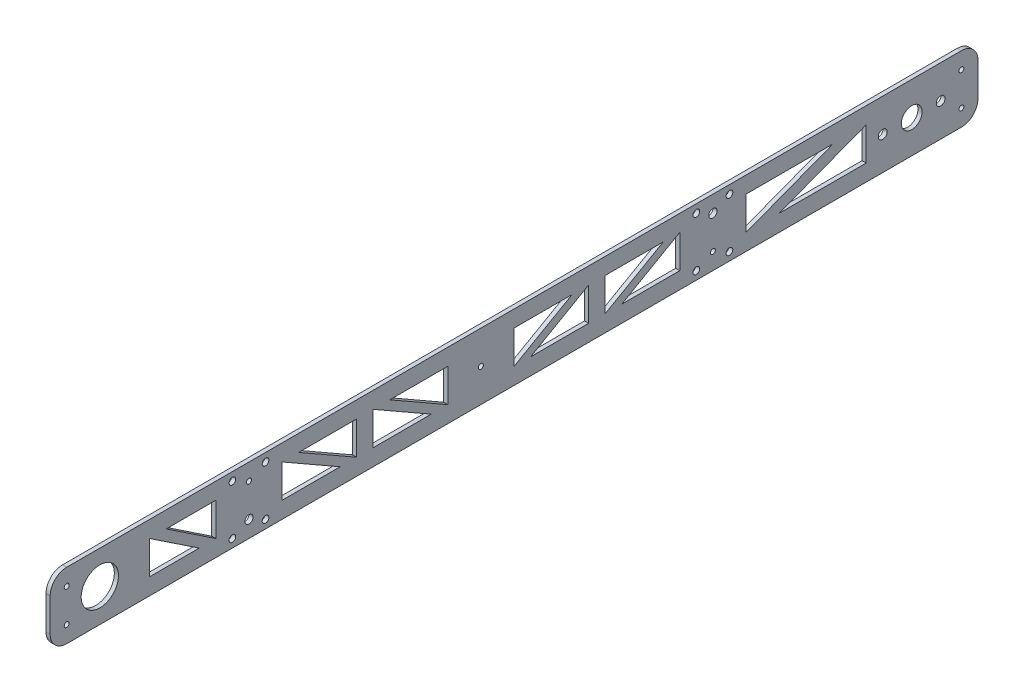
from build123d import *

# Parameters (mm, degrees)
SKETCH1_R           = 7.9629
SKETCH1_R_2         = 3.3782
SKETCH1_R_3         = 2.5527
SKETCH1_R_4         = 14.2875
SKETCH1_R_5         = 1.89865
SKETCH1_R_6         = 3.1496
SKETCH1_R_7         = 3.175
BOSS_EXTRUDE1_DEPTH = 3.175


with BuildPart() as part:
    # Sketch1 → Boss-Extrude1 (new body)
    with BuildSketch(Plane(origin=(0, 0, 0), x_dir=(0, 0, -1), z_dir=(1, 0, 0))):
        with BuildLine():
            Line((-12.7, 0), (-698.5, 0))
            ThreePointArc((-698.5, 0), (-707.480256121, 3.719743879), (-711.2, 12.7))
            Line((-711.2, 12.7), (-711.2, 38.1))
            ThreePointArc((-711.2, 38.1), (-707.480256121, 47.080256121), (-698.5, 50.8))
            Line((-698.5, 50.8), (-12.7, 50.8))
            ThreePointArc((-12.7, 50.8), (-3.719743879, 47.080256121), (0, 38.1))
            Line((0, 38.1), (0, 12.7))
            ThreePointArc((0, 12.7), (-3.719743879, 3.719743879), (-12.7, 0))
        make_face()
        with Locations((-50.8, 25.4)):
            Circle(SKETCH1_R, mode=Mode.SUBTRACT)
        with Locations((-28.575, 25.4)):
            Circle(SKETCH1_R_2, mode=Mode.SUBTRACT)
        with Locations((-215.9, 44.45)):
            Circle(SKETCH1_R_3, mode=Mode.SUBTRACT)
        with Locations((-190.5, 44.45)):
            Circle(SKETCH1_R_3, mode=Mode.SUBTRACT)
        with Locations((-190.5, 6.35)):
            Circle(SKETCH1_R_3, mode=Mode.SUBTRACT)
        with Locations((-215.9, 6.35)):
            Circle(SKETCH1_R_3, mode=Mode.SUBTRACT)
        with Locations((-73.025, 25.4)):
            Circle(SKETCH1_R_2, mode=Mode.SUBTRACT)
        with Locations((-673.1, 25.4)):
            Circle(SKETCH1_R_4, mode=Mode.SUBTRACT)
        with Locations((-571.5, 44.45)):
            Circle(SKETCH1_R_3, mode=Mode.SUBTRACT)
        with Locations((-546.1, 44.45)):
            Circle(SKETCH1_R_3, mode=Mode.SUBTRACT)
        with Locations((-12.7, 38.1)):
            Circle(SKETCH1_R_5, mode=Mode.SUBTRACT)
        with Locations((-12.7, 12.7)):
            Circle(SKETCH1_R_5, mode=Mode.SUBTRACT)
        with Locations((-546.1, 6.35)):
            Circle(SKETCH1_R_3, mode=Mode.SUBTRACT)
        with Locations((-571.5, 6.35)):
            Circle(SKETCH1_R_3, mode=Mode.SUBTRACT)
        with Locations((-558.8, 12.7)):
            Circle(SKETCH1_R_6, mode=Mode.SUBTRACT)
        with Locations((-203.2, 38.1)):
            Circle(SKETCH1_R_7, mode=Mode.SUBTRACT)
        with Locations((-698.5, 38.1)):
            Circle(SKETCH1_R_5, mode=Mode.SUBTRACT)
        with Locations((-698.5, 12.7)):
            Circle(SKETCH1_R_5, mode=Mode.SUBTRACT)
        with Locations((-558.8, 38.1)):
            Circle(SKETCH1_R_5, mode=Mode.SUBTRACT)
        with Locations((-203.2, 12.7)):
            Circle(SKETCH1_R_5, mode=Mode.SUBTRACT)
        with Locations((-381, 25.4)):
            Circle(SKETCH1_R_5, mode=Mode.SUBTRACT)
        Polygon((-228.6, 38.1), (-228.6, 12.7), (-273.05, 12.7), align=None, mode=Mode.SUBTRACT)
        Polygon((-635, 38.1), (-635, 12.7), (-596.9, 12.7), align=None, mode=Mode.SUBTRACT)
        Polygon((-622.3, 38.1), (-584.2, 38.1), (-584.2, 12.7), align=None, mode=Mode.SUBTRACT)
        Polygon((-533.4, 38.1), (-533.4, 12.7), (-488.95, 12.7), align=None, mode=Mode.SUBTRACT)
        Polygon((-406.4, 38.1), (-406.4, 12.7), (-450.85, 38.1), align=None, mode=Mode.SUBTRACT)
        Polygon((-419.1, 12.7), (-463.55, 38.1), (-463.55, 12.7), align=None, mode=Mode.SUBTRACT)
        Polygon((-476.25, 12.7), (-476.25, 38.1), (-520.7, 38.1), align=None, mode=Mode.SUBTRACT)
        Polygon((-241.3, 38.1), (-285.75, 12.7), (-285.75, 38.1), align=None, mode=Mode.SUBTRACT)
        Polygon((-298.45, 38.1), (-298.45, 12.7), (-342.9, 12.7), align=None, mode=Mode.SUBTRACT)
        Polygon((-355.6, 38.1), (-355.6, 12.7), (-311.15, 38.1), align=None, mode=Mode.SUBTRACT)
        Polygon((-177.8, 38.1), (-177.8, 12.7), (-111.125, 38.1), align=None, mode=Mode.SUBTRACT)
        Polygon((-85.725, 38.1), (-85.725, 12.7), (-152.4, 12.7), align=None, mode=Mode.SUBTRACT)
    extrude(amount=BOSS_EXTRUDE1_DEPTH)


solid = part.part
